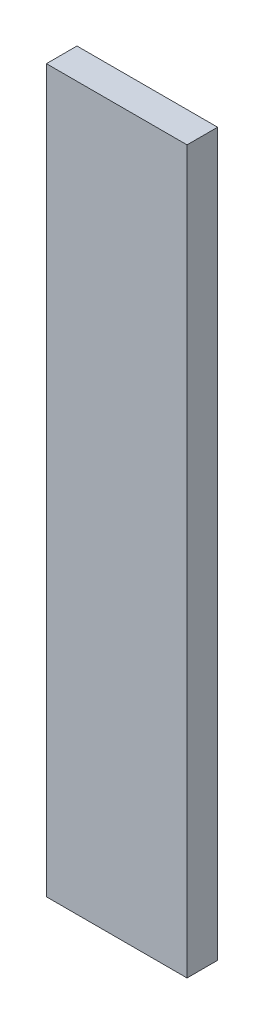
from build123d import *

# Parameters (mm, degrees)
SKETCH1_W           = 46
SKETCH1_H           = 236
BOSS_EXTRUDE1_DEPTH = 10


with BuildPart() as part:
    # Sketch1 → Boss-Extrude1 (new body)
    with BuildSketch(Plane.XY):
        with Locations((23, -72)):
            Rectangle(SKETCH1_W, SKETCH1_H)
    extrude(amount=BOSS_EXTRUDE1_DEPTH)


solid = part.part
